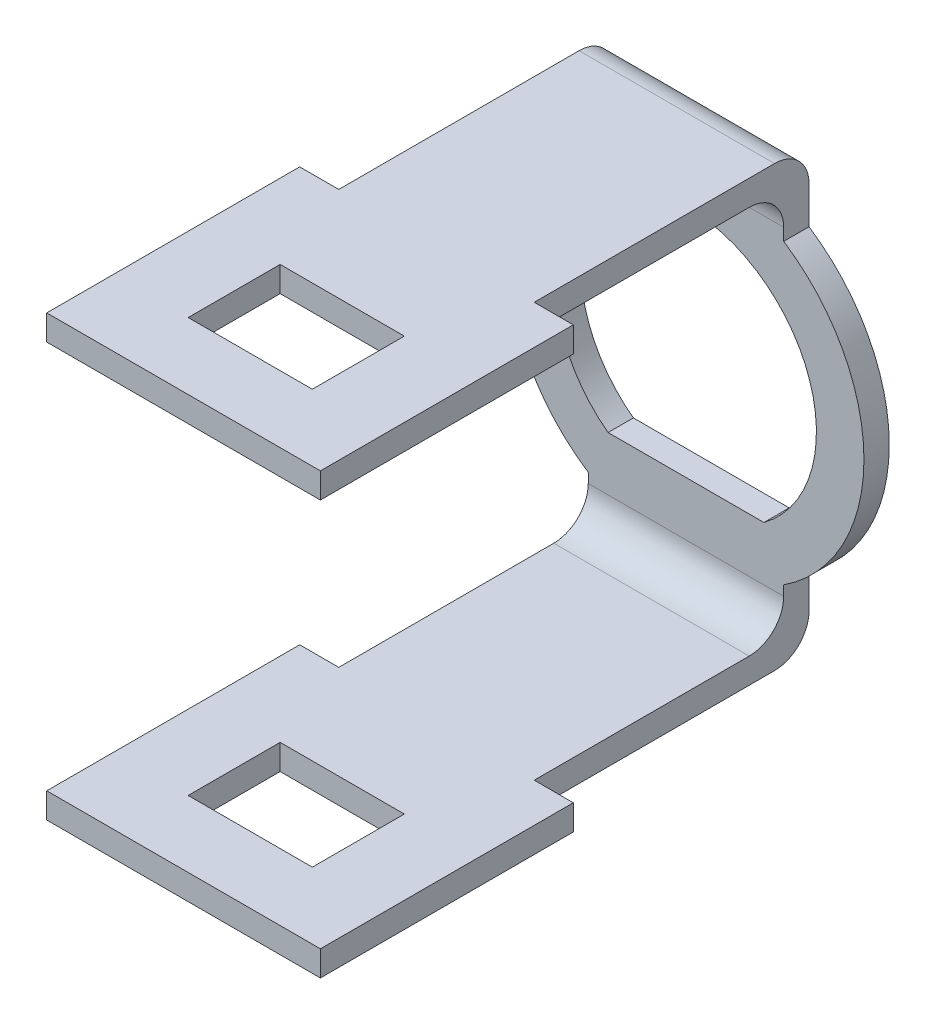
from build123d import *

# Parameters (mm, degrees)
BOSS_EXTRUDE1_DEPTH = 1.1
SKETCH3_W           = 11.9
SKETCH3_H           = 11
SKETCH3_W_2         = 5.4
SKETCH3_H_2         = 4
BOSS_EXTRUDE2_DEPTH = 1.1
SKETCH4_W           = 11.9
SKETCH4_H           = 11
SKETCH4_W_2         = 5.4
SKETCH4_H_2         = 4
BOSS_EXTRUDE3_DEPTH = 1.1
BOSS_EXTRUDE4_DEPTH = 4.25


with BuildPart() as part:
    # Sketch1 → Boss-Extrude1 (new body)
    with BuildSketch(Plane.XY):
        with BuildLine():
            Line((3.951985261, -6.654962537), (-3.971646211, -6.654962537))
            ThreePointArc((-3.971646211, -6.654962537), (-7.748260545, -0.1641905), (-4.25, 6.480740698))
            Line((-4.25, 6.480740698), (4.25, 6.468710372))
            ThreePointArc((4.25, 6.468710372), (7.737947933, -0.175714722), (3.951985261, -6.654962537))
        make_face()
        with BuildLine():
            Line((-3.388637081, -4.549455129), (3.388637081, -4.549455129))
            ThreePointArc((3.388637081, -4.549455129), (0, 5.672777383), (-3.388637081, -4.549455129))
        make_face(mode=Mode.SUBTRACT)
    extrude(amount=BOSS_EXTRUDE1_DEPTH)



with BuildPart() as body_2:
    # Sketch3 → Boss-Extrude2 (new body)
    with BuildSketch(Plane(origin=(0, -8.4, 0), x_dir=(-1, 0, 0), z_dir=(0, -1, 0))):
        with Locations((0, -17.45)):
            Rectangle(SKETCH3_W, SKETCH3_H)
        with Locations((0, -18.05)):
            Rectangle(SKETCH3_W_2, SKETCH3_H_2, mode=Mode.SUBTRACT)
    extrude(amount=BOSS_EXTRUDE2_DEPTH)


with BuildPart() as body_3:
    # Sketch4 → Boss-Extrude3 (new body)
    with BuildSketch(Plane(origin=(0, 8.5, 0), x_dir=(1, 0, 0), z_dir=(0, 1, 0))):
        with Locations((0, -17.45)):
            Rectangle(SKETCH4_W, SKETCH4_H)
        with Locations((0, -18.05)):
            Rectangle(SKETCH4_W_2, SKETCH4_H_2, mode=Mode.SUBTRACT)
    extrude(amount=BOSS_EXTRUDE3_DEPTH)


with BuildPart() as part_1:
    add(part.part)

    add(body_2.part)  # Boss-Extrude4 merges body 2

    add(body_3.part)  # Boss-Extrude4 merges body 3
    # Sketch2 → Boss-Extrude4 (add, symmetric)
    with BuildSketch(Plane(origin=(0, 0, 0), x_dir=(0, 0, -1), z_dir=(1, 0, 0))):
        with BuildLine():
            Line((-1.1, -6.245079779), (0, -6.245079779))
            Line((0, -6.245079779), (0, -8))
            ThreePointArc((0, -8), (-0.439339828, -9.060660172), (-1.5, -9.5))
            Line((-1.5, -9.5), (-11.95, -9.5))
            Line((-11.95, -9.5), (-11.95, -8.4))
            Line((-11.95, -8.4), (-2.6, -8.4))
            ThreePointArc((-2.6, -8.4), (-1.539339828, -7.960660172), (-1.1, -6.9))
            Line((-1.1, -6.9), (-1.1, -6.245079779))
        make_face()
        with BuildLine():
            Line((-1.1, 6.20982384), (0, 6.20982384))
            Line((0, 6.20982384), (0, 8.1))
            ThreePointArc((0, 8.1), (-0.439339828, 9.160660172), (-1.5, 9.6))
            Line((-1.5, 9.6), (-11.95, 9.6))
            Line((-11.95, 9.6), (-11.95, 8.5))
            Line((-11.95, 8.5), (-2.6, 8.5))
            ThreePointArc((-2.6, 8.5), (-1.539339828, 8.060660172), (-1.1, 7))
            Line((-1.1, 7), (-1.1, 6.20982384))
        make_face()
    extrude(amount=BOSS_EXTRUDE4_DEPTH, both=True)


solid = part_1.part
